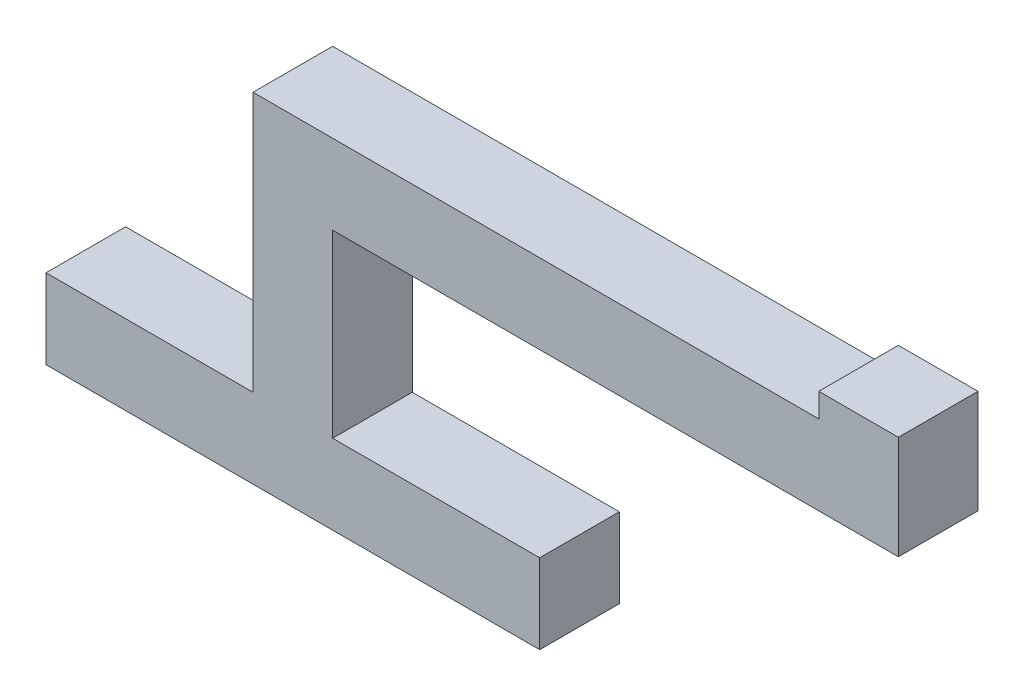
from build123d import *

# Parameters (mm, degrees)
BOSS_EXTRUDE1_DEPTH = 10


with BuildPart() as part:
    # Sketch2 → Boss-Extrude1 (new body)
    with BuildSketch(Plane.XY):
        Polygon((-63.83420123, 8.116846993), (-63.83420123, -1.883153007), (-1.83420123, -1.883153007), (-1.83420123, 8.116846993), (-27.83420123, 8.116846993), (-27.83420123, 30.747532628), (2.42414736, 30.747532628), (43.215736153, 30.747532628), (43.215736153, 43.747532628), (33.215736153, 43.747532628), (33.215736153, 40.747532628), (-37.83420123, 40.747532628), (-37.83420123, 8.116846993), align=None)
    extrude(amount=BOSS_EXTRUDE1_DEPTH)


solid = part.part
